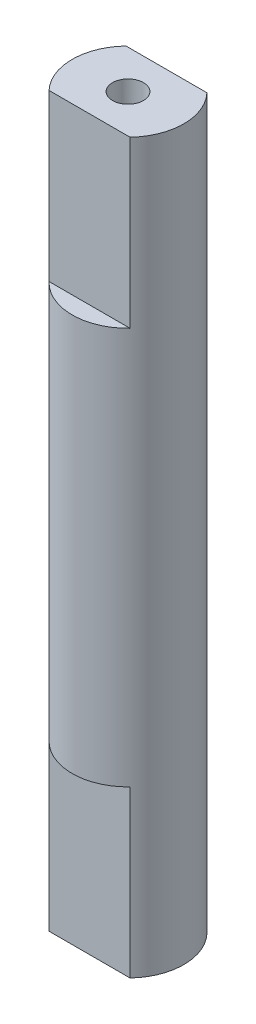
from build123d import *

# Parameters (mm, degrees)
ESQUISSE2_W             = 4
ESQUISSE2_H             = 1
ENL_V_MAT_EXTRU_1_DEPTH = 8


with BuildPart() as part:
    # Esquisse1 → Révolution1 (revolve)
    with BuildSketch(Plane.XY, mode=Mode.PRIVATE) as r_volution1_sk:
        Polygon((-2.7, 17.6), (-2.7, -17.6), (-0.75, -17.6), (-0.75, -9.6), (0, -9.166987298), (0, 9.166987298), (-0.75, 9.6), (-0.75, 17.6), align=None)
    revolve(r_volution1_sk.sketch.rotate(Axis((0, 24.604534005, 0), (0, -1, 0)), 270), axis=Axis((0, 24.604534005, 0), (0, -1, 0)))  # turned: the seam where the file's is

    # Esquisse2 → Enlèv. mat.-Extru.1 (cut)
    with BuildSketch(Plane(origin=(0, 17.6, 0), x_dir=(1, 0, 0), z_dir=(0, 1, 0))):
        with Locations((0, 2.36)):
            Rectangle(ESQUISSE2_W, ESQUISSE2_H)
        with Locations((0, -2.36)):
            Rectangle(ESQUISSE2_W, ESQUISSE2_H)
    enl_v_mat_extru_1 = extrude(amount=-ENL_V_MAT_EXTRU_1_DEPTH, mode=Mode.SUBTRACT)

    # Symétrie1: Enlèv. mat.-Extru.1 across plane
    add(enl_v_mat_extru_1.mirror(Plane.ZX), mode=Mode.SUBTRACT)


solid = part.part
